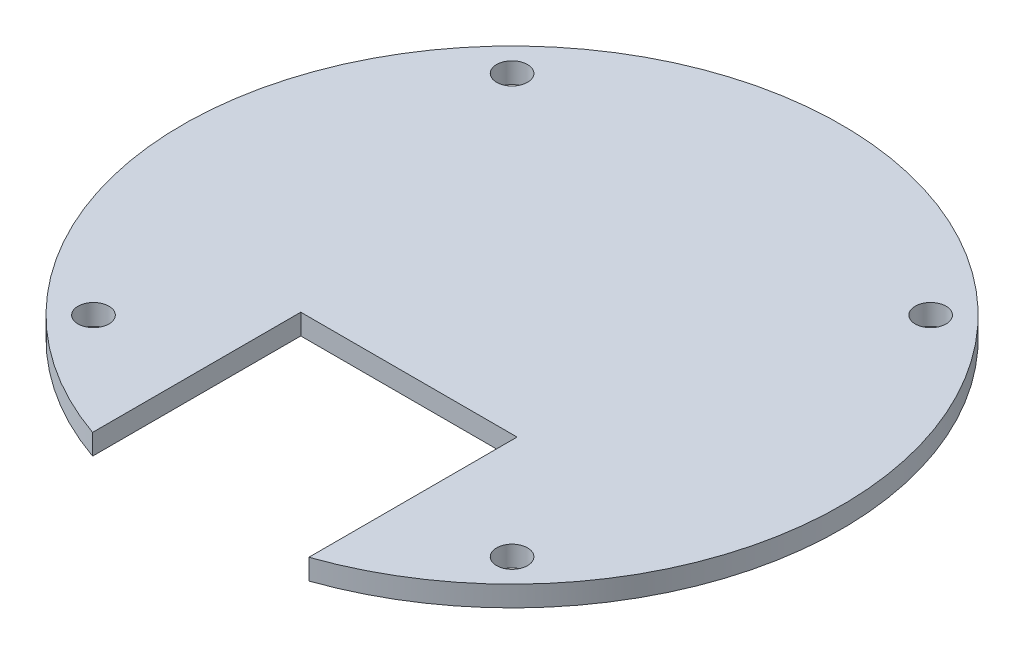
from build123d import *

# Parameters (mm, degrees)
CROQUIS1_R              = 1.5
SALIENTE_EXTRUIR2_DEPTH = 2


with BuildPart() as part:
    # Croquis1 → Saliente-Extruir2 (new body)
    with BuildSketch(Plane(origin=(0, 0, 0), x_dir=(1, 0, 0), z_dir=(0, 1, 0))):
        with BuildLine():
            Line((10.296518832, -10.234095306), (10.296518832, -30.447615579))
            ThreePointArc((10.296518832, -30.447615579), (-0.203481168, 31.780682421), (-10.703481168, -30.447615579))
            Line((-10.703481168, -30.447615579), (-10.703481168, -10.234095306))
            Line((-10.703481168, -10.234095306), (10.296518832, -10.234095306))
        make_face()
        with Locations((-20.524295325, 20.101496578)):
            Circle(CROQUIS1_R, mode=Mode.SUBTRACT)
        with Locations((20.117332989, 20.101496578)):
            Circle(CROQUIS1_R, mode=Mode.SUBTRACT)
        with Locations((20.117332989, -20.540131736)):
            Circle(CROQUIS1_R, mode=Mode.SUBTRACT)
        with Locations((-20.524295325, -20.540131736)):
            Circle(CROQUIS1_R, mode=Mode.SUBTRACT)
    extrude(amount=SALIENTE_EXTRUIR2_DEPTH)


solid = part.part
